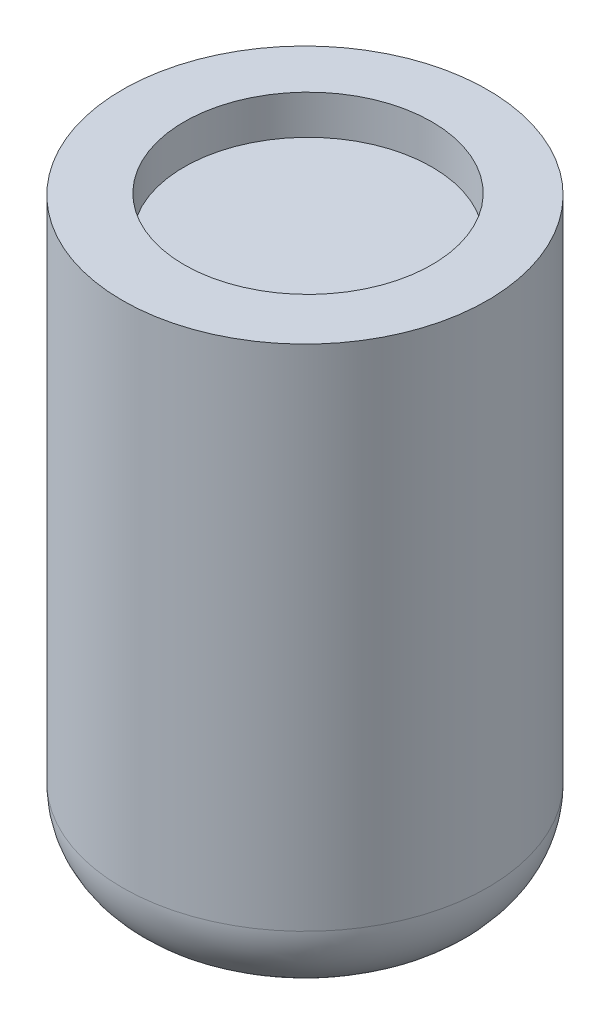
from build123d import *

# Parameters (mm, degrees)
SKETCH_1_R          = 2.8
EXTRUDE_1_DEPTH     = 9
SKETCH_2_R          = 1.9
CUT_EXTRUDE_1_DEPTH = 0.6
FILLET_1_R          = 1.2


with BuildPart() as part:
    # Эскиз1 → Бобышка-Вытянуть1 (new body)
    with BuildSketch(Plane(origin=(0, 0, 0), x_dir=(1, 0, 0), z_dir=(0, 1, 0))):
        Circle(SKETCH_1_R)
    extrude(amount=EXTRUDE_1_DEPTH)

    # Эскиз2 → Вырез-Вытянуть1 (cut)
    with BuildSketch(Plane(origin=(0, 9, 0), x_dir=(1, 0, 0), z_dir=(0, 1, 0))):
        with Locations((0, 0.047154172)):
            Circle(SKETCH_2_R)
    extrude(amount=-CUT_EXTRUDE_1_DEPTH, mode=Mode.SUBTRACT)

    # Скругление1
    fillet_1_edges = [part.edges().sort_by_distance(p)[0] for p in [
        (-2.8, 0, 0),
    ]]
    fillet(fillet_1_edges, radius=FILLET_1_R)


solid = part.part
